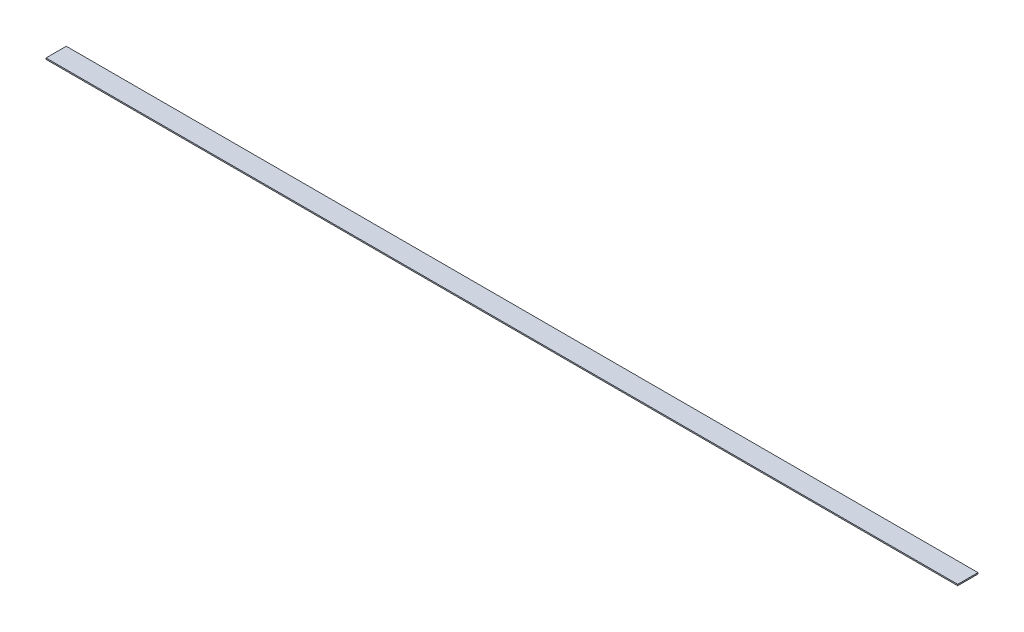
from build123d import *

# Parameters (mm, degrees)
SKETCH1_W           = 1143
SKETCH1_H           = 25.4
BOSS_EXTRUDE1_DEPTH = 1.5875


with BuildPart() as part:
    # Sketch1 → Boss-Extrude1 (new body)
    with BuildSketch(Plane(origin=(0, 0, 0), x_dir=(1, 0, 0), z_dir=(0, 1, 0))):
        Rectangle(SKETCH1_W, SKETCH1_H)
    extrude(amount=BOSS_EXTRUDE1_DEPTH)


solid = part.part
